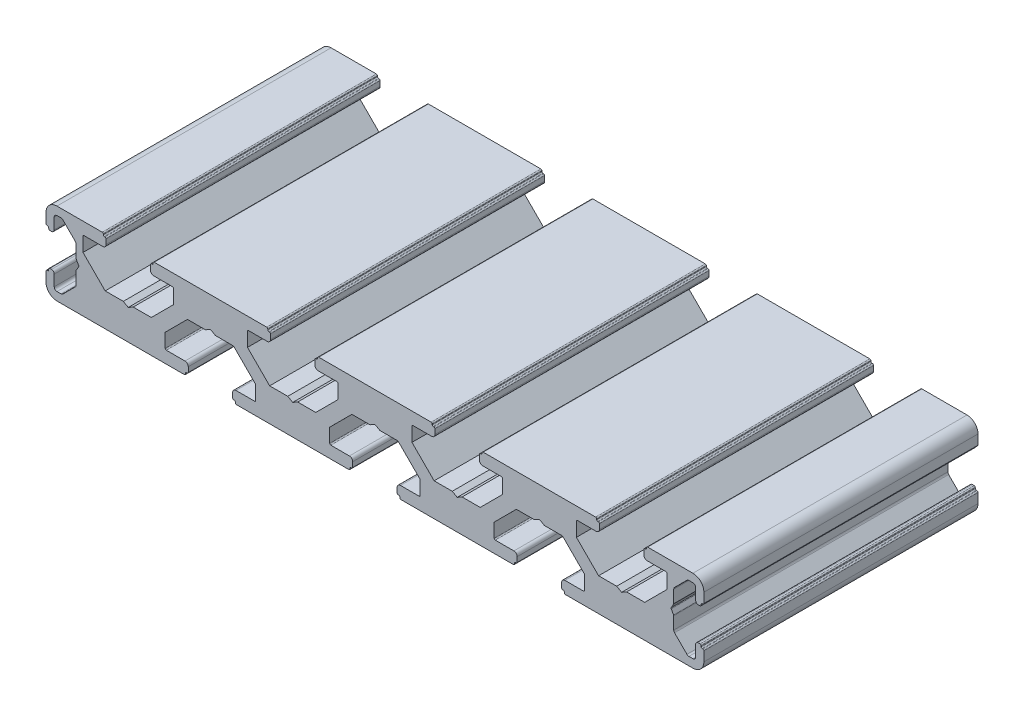
from build123d import *

# Parameters (mm, degrees)
DODANIE_WYCI_GNI_CIE1_DEPTH = 50


with BuildPart() as part:
    # Szkic1 → Dodanie-wyciągnięcie1 (new body)
    with BuildSketch(Plane.XY):
        with BuildLine():
            Line((141.56, 44.575148163), (142.459999946, 44.06))
            Line((142.459999946, 44.06), (145.764466193, 44.06))
            Line((145.764466193, 44.06), (149.810000327, 40.010000763))
            Line((149.810000327, 40.010000763), (149.810000327, 37.460001166))
            ThreePointArc((149.810000327, 37.460001166), (149.751421565, 37.318579525), (149.609999924, 37.260000763))
            Line((149.609999924, 37.260000763), (146.210000197, 37.260000763))
            ThreePointArc((146.210000197, 37.260000763), (145.785735989, 37.084264774), (145.61, 36.660000566))
            Line((145.61, 36.660000566), (145.61, 35.760000374))
            ThreePointArc((145.61, 35.760000374), (145.668578753, 35.618578753), (145.810000374, 35.56))
            Line((145.810000374, 35.56), (145.910000144, 35.56))
            ThreePointArc((145.910000144, 35.56), (146.05142109, 35.501421526), (146.109999564, 35.36000058))
            Line((146.109999564, 35.36000058), (146.109999564, 35.260000381))
            ThreePointArc((146.109999564, 35.260000381), (146.16857832, 35.118578755), (146.309999945, 35.06))
            Line((146.309999945, 35.06), (166.810000055, 35.06))
            ThreePointArc((166.810000055, 35.06), (166.95142168, 35.118578755), (167.010000436, 35.260000381))
            Line((167.010000436, 35.260000381), (167.010000436, 35.36000058))
            ThreePointArc((167.010000436, 35.36000058), (167.06857891, 35.501421526), (167.209999856, 35.56))
            Line((167.209999856, 35.56), (167.309999626, 35.56))
            ThreePointArc((167.309999626, 35.56), (167.451421247, 35.618578753), (167.51, 35.760000374))
            Line((167.51, 35.760000374), (167.51, 36.660000566))
            ThreePointArc((167.51, 36.660000566), (167.334264011, 37.084264774), (166.909999803, 37.260000763))
            Line((166.909999803, 37.260000763), (163.510000076, 37.260000763))
            ThreePointArc((163.510000076, 37.260000763), (163.368578435, 37.318579525), (163.309999673, 37.460001166))
            Line((163.309999673, 37.460001166), (163.309999673, 40.010000763))
            Line((163.309999673, 40.010000763), (167.355533807, 44.06))
            Line((167.355533807, 44.06), (170.660000054, 44.06))
            Line((170.660000054, 44.06), (171.56, 44.575148163))
            Line((171.56, 44.575148163), (172.459999946, 44.06))
            Line((172.459999946, 44.06), (175.764466193, 44.06))
            Line((175.764466193, 44.06), (179.810000327, 40.010000763))
            Line((179.810000327, 40.010000763), (179.810000327, 37.460001166))
            ThreePointArc((179.810000327, 37.460001166), (179.751421565, 37.318579525), (179.609999924, 37.260000763))
            Line((179.609999924, 37.260000763), (176.210000197, 37.260000763))
            ThreePointArc((176.210000197, 37.260000763), (175.785735989, 37.084264774), (175.61, 36.660000566))
            Line((175.61, 36.660000566), (175.61, 35.760000374))
            ThreePointArc((175.61, 35.760000374), (175.668578753, 35.618578753), (175.810000374, 35.56))
            Line((175.810000374, 35.56), (175.910000144, 35.56))
            ThreePointArc((175.910000144, 35.56), (176.05142109, 35.501421526), (176.109999564, 35.36000058))
            Line((176.109999564, 35.36000058), (176.109999564, 35.260000381))
            ThreePointArc((176.109999564, 35.260000381), (176.16857832, 35.118578755), (176.309999945, 35.06))
            Line((176.309999945, 35.06), (199.56, 35.06))
            ThreePointArc((199.56, 35.06), (200.974213562, 35.645786438), (201.56, 37.06))
            Line((201.56, 37.06), (201.56, 38.810000395))
            ThreePointArc((201.56, 38.810000395), (201.501421356, 38.951421752), (201.36, 39.010000395))
            Line((201.36, 39.010000395), (201.259999732, 39.010000395))
            ThreePointArc((201.259999732, 39.010000395), (201.118578376, 39.068579039), (201.059999732, 39.210000395))
            Line((201.059999732, 39.210000395), (201.059999732, 39.36))
            ThreePointArc((201.059999732, 39.36), (201.001421088, 39.501421356), (200.859999732, 39.56))
            Line((200.859999732, 39.56), (200.559999732, 39.56))
            ThreePointArc((200.559999732, 39.56), (200.206446341, 39.413553391), (200.059999732, 39.06))
            Line((200.059999732, 39.06), (200.059999732, 37.060000395))
            ThreePointArc((200.059999732, 37.060000395), (199.913553123, 36.706447005), (199.559999732, 36.560000395))
            Line((199.559999732, 36.560000395), (198.827766685, 36.560000395))
            ThreePointArc((198.827766685, 36.560000395), (198.636424969, 36.598060629), (198.474213294, 36.706447005))
            Line((198.474213294, 36.706447005), (196.206446398, 38.974213901))
            ThreePointArc((196.206446398, 38.974213901), (196.098060023, 39.136425575), (196.059999789, 39.327767291))
            Line((196.059999789, 39.327767291), (196.059999789, 41.606410698))
            ThreePointArc((196.059999789, 41.606410698), (196.053184953, 41.65817451), (196.033204867, 41.706410702))
            Line((196.033204867, 41.706410702), (195.598119841, 42.460000031))
            ThreePointArc((195.598119841, 42.460000031), (195.571324929, 42.56), (195.598119841, 42.659999969))
            Line((195.598119841, 42.659999969), (196.033204867, 43.413589297))
            ThreePointArc((196.033204867, 43.413589297), (196.053184953, 43.46182549), (196.059999789, 43.513589302))
            Line((196.059999789, 43.513589302), (196.059999789, 45.792232708))
            ThreePointArc((196.059999789, 45.792232708), (196.098060023, 45.983574425), (196.206446398, 46.145786099))
            Line((196.206446398, 46.145786099), (198.474213294, 48.413552995))
            ThreePointArc((198.474213294, 48.413552995), (198.636424969, 48.521939371), (198.827766685, 48.559999605))
            Line((198.827766685, 48.559999605), (199.559999732, 48.559999605))
            ThreePointArc((199.559999732, 48.559999605), (199.913553123, 48.413552995), (200.059999732, 48.059999605))
            Line((200.059999732, 48.059999605), (200.059999732, 46.06))
            ThreePointArc((200.059999732, 46.06), (200.206446341, 45.706446609), (200.559999732, 45.56))
            Line((200.559999732, 45.56), (200.859999732, 45.56))
            ThreePointArc((200.859999732, 45.56), (201.001421088, 45.618578644), (201.059999732, 45.76))
            Line((201.059999732, 45.76), (201.059999732, 45.909999605))
            ThreePointArc((201.059999732, 45.909999605), (201.118578376, 46.051420961), (201.259999732, 46.109999605))
            Line((201.259999732, 46.109999605), (201.36, 46.109999605))
            ThreePointArc((201.36, 46.109999605), (201.501421356, 46.168578248), (201.56, 46.309999605))
            Line((201.56, 46.309999605), (201.56, 48.06))
            ThreePointArc((201.56, 48.06), (200.974213562, 49.474213562), (199.56, 50.06))
            Line((199.56, 50.06), (191.309999945, 50.06))
            ThreePointArc((191.309999945, 50.06), (191.16857832, 50.001421245), (191.109999564, 49.859999619))
            Line((191.109999564, 49.859999619), (191.109999564, 49.75999942))
            ThreePointArc((191.109999564, 49.75999942), (191.05142109, 49.618578474), (190.910000144, 49.56))
            Line((190.910000144, 49.56), (190.810000374, 49.56))
            ThreePointArc((190.810000374, 49.56), (190.668578753, 49.501421247), (190.61, 49.359999626))
            Line((190.61, 49.359999626), (190.61, 48.459999434))
            ThreePointArc((190.61, 48.459999434), (190.785735989, 48.035735226), (191.210000197, 47.859999237))
            Line((191.210000197, 47.859999237), (194.609999924, 47.859999237))
            ThreePointArc((194.609999924, 47.859999237), (194.751421565, 47.801420475), (194.810000327, 47.659998834))
            Line((194.810000327, 47.659998834), (194.810000327, 45.109999237))
            Line((194.810000327, 45.109999237), (190.764466193, 41.06))
            Line((190.764466193, 41.06), (187.459999946, 41.06))
            Line((187.459999946, 41.06), (186.56, 40.544851837))
            Line((186.56, 40.544851837), (185.660000054, 41.06))
            Line((185.660000054, 41.06), (182.355533807, 41.06))
            Line((182.355533807, 41.06), (178.309999673, 45.109999237))
            Line((178.309999673, 45.109999237), (178.309999673, 47.659998834))
            ThreePointArc((178.309999673, 47.659998834), (178.368578435, 47.801420475), (178.510000076, 47.859999237))
            Line((178.510000076, 47.859999237), (181.909999803, 47.859999237))
            ThreePointArc((181.909999803, 47.859999237), (182.334264011, 48.035735226), (182.51, 48.459999434))
            Line((182.51, 48.459999434), (182.51, 49.359999626))
            ThreePointArc((182.51, 49.359999626), (182.451421247, 49.501421247), (182.309999626, 49.56))
            Line((182.309999626, 49.56), (182.209999856, 49.56))
            ThreePointArc((182.209999856, 49.56), (182.06857891, 49.618578474), (182.010000436, 49.75999942))
            Line((182.010000436, 49.75999942), (182.010000436, 49.859999619))
            ThreePointArc((182.010000436, 49.859999619), (181.95142168, 50.001421245), (181.810000055, 50.06))
            Line((181.810000055, 50.06), (161.309999945, 50.06))
            ThreePointArc((161.309999945, 50.06), (161.16857832, 50.001421245), (161.109999564, 49.859999619))
            Line((161.109999564, 49.859999619), (161.109999564, 49.75999942))
            ThreePointArc((161.109999564, 49.75999942), (161.05142109, 49.618578474), (160.910000144, 49.56))
            Line((160.910000144, 49.56), (160.810000374, 49.56))
            ThreePointArc((160.810000374, 49.56), (160.668578753, 49.501421247), (160.61, 49.359999626))
            Line((160.61, 49.359999626), (160.61, 48.459999434))
            ThreePointArc((160.61, 48.459999434), (160.785735989, 48.035735226), (161.210000197, 47.859999237))
            Line((161.210000197, 47.859999237), (164.609999924, 47.859999237))
            ThreePointArc((164.609999924, 47.859999237), (164.751421565, 47.801420475), (164.810000327, 47.659998834))
            Line((164.810000327, 47.659998834), (164.810000327, 45.109999237))
            Line((164.810000327, 45.109999237), (160.764466193, 41.06))
            Line((160.764466193, 41.06), (157.459999946, 41.06))
            Line((157.459999946, 41.06), (156.56, 40.544851837))
            Line((156.56, 40.544851837), (155.660000054, 41.06))
            Line((155.660000054, 41.06), (152.355533807, 41.06))
            Line((152.355533807, 41.06), (148.309999673, 45.109999237))
            Line((148.309999673, 45.109999237), (148.309999673, 47.659998834))
            ThreePointArc((148.309999673, 47.659998834), (148.368578435, 47.801420475), (148.510000076, 47.859999237))
            Line((148.510000076, 47.859999237), (151.909999803, 47.859999237))
            ThreePointArc((151.909999803, 47.859999237), (152.334264011, 48.035735226), (152.51, 48.459999434))
            Line((152.51, 48.459999434), (152.51, 49.359999626))
            ThreePointArc((152.51, 49.359999626), (152.451421247, 49.501421247), (152.309999626, 49.56))
            Line((152.309999626, 49.56), (152.209999856, 49.56))
            ThreePointArc((152.209999856, 49.56), (152.06857891, 49.618578474), (152.010000436, 49.75999942))
            Line((152.010000436, 49.75999942), (152.010000436, 49.859999619))
            ThreePointArc((152.010000436, 49.859999619), (151.95142168, 50.001421245), (151.810000055, 50.06))
            Line((151.810000055, 50.06), (131.309999945, 50.06))
            ThreePointArc((131.309999945, 50.06), (131.16857832, 50.001421245), (131.109999564, 49.859999619))
            Line((131.109999564, 49.859999619), (131.109999564, 49.75999942))
            ThreePointArc((131.109999564, 49.75999942), (131.05142109, 49.618578474), (130.910000144, 49.56))
            Line((130.910000144, 49.56), (130.810000374, 49.56))
            ThreePointArc((130.810000374, 49.56), (130.668578753, 49.501421247), (130.61, 49.359999626))
            Line((130.61, 49.359999626), (130.61, 48.459999434))
            ThreePointArc((130.61, 48.459999434), (130.785735989, 48.035735226), (131.210000197, 47.859999237))
            Line((131.210000197, 47.859999237), (134.609999924, 47.859999237))
            ThreePointArc((134.609999924, 47.859999237), (134.751421565, 47.801420475), (134.810000327, 47.659998834))
            Line((134.810000327, 47.659998834), (134.810000327, 45.109999237))
            Line((134.810000327, 45.109999237), (130.764466193, 41.06))
            Line((130.764466193, 41.06), (127.459999946, 41.06))
            Line((127.459999946, 41.06), (126.56, 40.544851837))
            Line((126.56, 40.544851837), (125.660000054, 41.06))
            Line((125.660000054, 41.06), (122.355533807, 41.06))
            Line((122.355533807, 41.06), (118.309999673, 45.109999237))
            Line((118.309999673, 45.109999237), (118.309999673, 47.659998834))
            ThreePointArc((118.309999673, 47.659998834), (118.368578435, 47.801420475), (118.510000076, 47.859999237))
            Line((118.510000076, 47.859999237), (121.909999803, 47.859999237))
            ThreePointArc((121.909999803, 47.859999237), (122.334264011, 48.035735226), (122.51, 48.459999434))
            Line((122.51, 48.459999434), (122.51, 49.359999626))
            ThreePointArc((122.51, 49.359999626), (122.451421247, 49.501421247), (122.309999626, 49.56))
            Line((122.309999626, 49.56), (122.209999856, 49.56))
            ThreePointArc((122.209999856, 49.56), (122.06857891, 49.618578474), (122.010000436, 49.75999942))
            Line((122.010000436, 49.75999942), (122.010000436, 49.859999619))
            ThreePointArc((122.010000436, 49.859999619), (121.95142168, 50.001421245), (121.810000055, 50.06))
            Line((121.810000055, 50.06), (101.309999945, 50.06))
            ThreePointArc((101.309999945, 50.06), (101.16857832, 50.001421245), (101.109999564, 49.859999619))
            Line((101.109999564, 49.859999619), (101.109999564, 49.75999942))
            ThreePointArc((101.109999564, 49.75999942), (101.05142109, 49.618578474), (100.910000144, 49.56))
            Line((100.910000144, 49.56), (100.810000374, 49.56))
            ThreePointArc((100.810000374, 49.56), (100.668578753, 49.501421247), (100.61, 49.359999626))
            Line((100.61, 49.359999626), (100.61, 48.459999434))
            ThreePointArc((100.61, 48.459999434), (100.785735989, 48.035735226), (101.210000197, 47.859999237))
            Line((101.210000197, 47.859999237), (104.609999924, 47.859999237))
            ThreePointArc((104.609999924, 47.859999237), (104.751421565, 47.801420475), (104.810000327, 47.659998834))
            Line((104.810000327, 47.659998834), (104.810000327, 45.109999237))
            Line((104.810000327, 45.109999237), (100.764466193, 41.06))
            Line((100.764466193, 41.06), (97.459999946, 41.06))
            Line((97.459999946, 41.06), (96.56, 40.544851837))
            Line((96.56, 40.544851837), (95.660000054, 41.06))
            Line((95.660000054, 41.06), (92.355533807, 41.06))
            Line((92.355533807, 41.06), (88.309999673, 45.109999237))
            Line((88.309999673, 45.109999237), (88.309999673, 47.659998834))
            ThreePointArc((88.309999673, 47.659998834), (88.368578435, 47.801420475), (88.510000076, 47.859999237))
            Line((88.510000076, 47.859999237), (91.909999803, 47.859999237))
            ThreePointArc((91.909999803, 47.859999237), (92.334264011, 48.035735226), (92.51, 48.459999434))
            Line((92.51, 48.459999434), (92.51, 49.359999626))
            ThreePointArc((92.51, 49.359999626), (92.451421247, 49.501421247), (92.309999626, 49.56))
            Line((92.309999626, 49.56), (92.209999856, 49.56))
            ThreePointArc((92.209999856, 49.56), (92.06857891, 49.618578474), (92.010000436, 49.75999942))
            Line((92.010000436, 49.75999942), (92.010000436, 49.859999619))
            ThreePointArc((92.010000436, 49.859999619), (91.95142168, 50.001421245), (91.810000055, 50.06))
            Line((91.810000055, 50.06), (83.56, 50.06))
            ThreePointArc((83.56, 50.06), (82.145786438, 49.474213562), (81.56, 48.06))
            Line((81.56, 48.06), (81.56, 46.309999605))
            ThreePointArc((81.56, 46.309999605), (81.618578644, 46.168578248), (81.76, 46.109999605))
            Line((81.76, 46.109999605), (81.860000268, 46.109999605))
            ThreePointArc((81.860000268, 46.109999605), (82.001421624, 46.051420961), (82.060000268, 45.909999605))
            Line((82.060000268, 45.909999605), (82.060000268, 45.76))
            ThreePointArc((82.060000268, 45.76), (82.118578912, 45.618578644), (82.260000268, 45.56))
            Line((82.260000268, 45.56), (82.560000268, 45.56))
            ThreePointArc((82.560000268, 45.56), (82.913553659, 45.706446609), (83.060000268, 46.06))
            Line((83.060000268, 46.06), (83.060000268, 48.059999605))
            ThreePointArc((83.060000268, 48.059999605), (83.206446877, 48.413552995), (83.560000268, 48.559999605))
            Line((83.560000268, 48.559999605), (84.292233315, 48.559999605))
            ThreePointArc((84.292233315, 48.559999605), (84.483575031, 48.521939371), (84.645786706, 48.413552995))
            Line((84.645786706, 48.413552995), (86.913553602, 46.145786099))
            ThreePointArc((86.913553602, 46.145786099), (87.021939977, 45.983574425), (87.060000211, 45.792232709))
            Line((87.060000211, 45.792232709), (87.060000211, 43.513589302))
            ThreePointArc((87.060000211, 43.513589302), (87.066815047, 43.46182549), (87.086795133, 43.413589298))
            Line((87.086795133, 43.413589298), (87.521880159, 42.659999969))
            ThreePointArc((87.521880159, 42.659999969), (87.548675071, 42.56), (87.521880159, 42.460000031))
            Line((87.521880159, 42.460000031), (87.086795133, 41.706410703))
            ThreePointArc((87.086795133, 41.706410703), (87.066815046, 41.65817451), (87.060000211, 41.606410698))
            Line((87.060000211, 41.606410698), (87.060000211, 39.327767292))
            ThreePointArc((87.060000211, 39.327767292), (87.021939977, 39.136425575), (86.913553602, 38.974213901))
            Line((86.913553602, 38.974213901), (84.645786706, 36.706447005))
            ThreePointArc((84.645786706, 36.706447005), (84.483575031, 36.598060629), (84.292233315, 36.560000395))
            Line((84.292233315, 36.560000395), (83.560000268, 36.560000395))
            ThreePointArc((83.560000268, 36.560000395), (83.206446877, 36.706447005), (83.060000268, 37.060000395))
            Line((83.060000268, 37.060000395), (83.060000268, 39.06))
            ThreePointArc((83.060000268, 39.06), (82.913553659, 39.413553391), (82.560000268, 39.56))
            Line((82.560000268, 39.56), (82.260000268, 39.56))
            ThreePointArc((82.260000268, 39.56), (82.118578912, 39.501421356), (82.060000268, 39.36))
            Line((82.060000268, 39.36), (82.060000268, 39.210000395))
            ThreePointArc((82.060000268, 39.210000395), (82.001421624, 39.068579039), (81.860000268, 39.010000395))
            Line((81.860000268, 39.010000395), (81.76, 39.010000395))
            ThreePointArc((81.76, 39.010000395), (81.618578644, 38.951421752), (81.56, 38.810000395))
            Line((81.56, 38.810000395), (81.56, 37.06))
            ThreePointArc((81.56, 37.06), (82.145786438, 35.645786438), (83.56, 35.06))
            Line((83.56, 35.06), (106.810000055, 35.06))
            ThreePointArc((106.810000055, 35.06), (106.95142168, 35.118578755), (107.010000436, 35.260000381))
            Line((107.010000436, 35.260000381), (107.010000436, 35.36000058))
            ThreePointArc((107.010000436, 35.36000058), (107.06857891, 35.501421526), (107.209999856, 35.56))
            Line((107.209999856, 35.56), (107.309999626, 35.56))
            ThreePointArc((107.309999626, 35.56), (107.451421247, 35.618578753), (107.51, 35.760000374))
            Line((107.51, 35.760000374), (107.51, 36.660000566))
            ThreePointArc((107.51, 36.660000566), (107.334264011, 37.084264774), (106.909999803, 37.260000763))
            Line((106.909999803, 37.260000763), (103.510000076, 37.260000763))
            ThreePointArc((103.510000076, 37.260000763), (103.368578435, 37.318579525), (103.309999673, 37.460001166))
            Line((103.309999673, 37.460001166), (103.309999673, 40.010000763))
            Line((103.309999673, 40.010000763), (107.355533807, 44.06))
            Line((107.355533807, 44.06), (110.660000054, 44.06))
            Line((110.660000054, 44.06), (111.56, 44.575148163))
            Line((111.56, 44.575148163), (112.459999946, 44.06))
            Line((112.459999946, 44.06), (115.764466193, 44.06))
            Line((115.764466193, 44.06), (119.810000327, 40.010000763))
            Line((119.810000327, 40.010000763), (119.810000327, 37.460001166))
            ThreePointArc((119.810000327, 37.460001166), (119.751421565, 37.318579525), (119.609999924, 37.260000763))
            Line((119.609999924, 37.260000763), (116.210000197, 37.260000763))
            ThreePointArc((116.210000197, 37.260000763), (115.785735989, 37.084264774), (115.61, 36.660000566))
            Line((115.61, 36.660000566), (115.61, 35.760000374))
            ThreePointArc((115.61, 35.760000374), (115.668578753, 35.618578753), (115.810000374, 35.56))
            Line((115.810000374, 35.56), (115.910000144, 35.56))
            ThreePointArc((115.910000144, 35.56), (116.05142109, 35.501421526), (116.109999564, 35.36000058))
            Line((116.109999564, 35.36000058), (116.109999564, 35.260000381))
            ThreePointArc((116.109999564, 35.260000381), (116.16857832, 35.118578755), (116.309999945, 35.06))
            Line((116.309999945, 35.06), (136.810000055, 35.06))
            ThreePointArc((136.810000055, 35.06), (136.95142168, 35.118578755), (137.010000436, 35.260000381))
            Line((137.010000436, 35.260000381), (137.010000436, 35.36000058))
            ThreePointArc((137.010000436, 35.36000058), (137.06857891, 35.501421526), (137.209999856, 35.56))
            Line((137.209999856, 35.56), (137.309999626, 35.56))
            ThreePointArc((137.309999626, 35.56), (137.451421247, 35.618578753), (137.51, 35.760000374))
            Line((137.51, 35.760000374), (137.51, 36.660000566))
            ThreePointArc((137.51, 36.660000566), (137.334264011, 37.084264774), (136.909999803, 37.260000763))
            Line((136.909999803, 37.260000763), (133.510000076, 37.260000763))
            ThreePointArc((133.510000076, 37.260000763), (133.368578435, 37.318579525), (133.309999673, 37.460001166))
            Line((133.309999673, 37.460001166), (133.309999673, 40.010000763))
            Line((133.309999673, 40.010000763), (137.355533807, 44.06))
            Line((137.355533807, 44.06), (140.660000054, 44.06))
            Line((140.660000054, 44.06), (141.56, 44.575148163))
        make_face()
    extrude(amount=DODANIE_WYCI_GNI_CIE1_DEPTH)


solid = part.part
